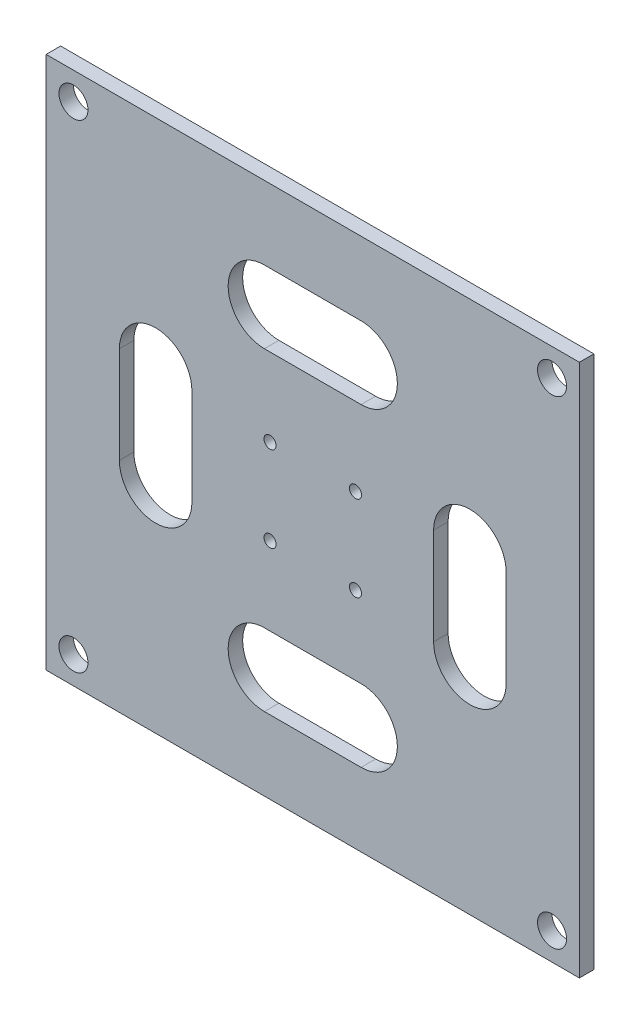
from build123d import *

# Parameters (mm, degrees)
CROQUIS3_W              = 110.308657866
CROQUIS3_H              = 110.308657866
CROQUIS3_R              = 1.25
CROQUIS3_R_2            = 3
SALIENTE_EXTRUIR1_DEPTH = 3


with BuildPart() as part:
    # Croquis3 → Saliente-Extruir1 (new body)
    with BuildSketch(Plane.XY):
        Rectangle(CROQUIS3_W, CROQUIS3_H)
        with Locations((-8.838834765, 8.838834765)):
            Circle(CROQUIS3_R, mode=Mode.SUBTRACT)
        with Locations((8.838834765, 8.838834765)):
            Circle(CROQUIS3_R, mode=Mode.SUBTRACT)
        with Locations((8.838834765, -8.838834765)):
            Circle(CROQUIS3_R, mode=Mode.SUBTRACT)
        with Locations((-8.838834765, -8.838834765)):
            Circle(CROQUIS3_R, mode=Mode.SUBTRACT)
        with Locations((-49.497474683, 49.497474683)):
            Circle(CROQUIS3_R_2, mode=Mode.SUBTRACT)
        with Locations((49.497474683, 49.497474683)):
            Circle(CROQUIS3_R_2, mode=Mode.SUBTRACT)
        with Locations((49.497474683, -49.497474683)):
            Circle(CROQUIS3_R_2, mode=Mode.SUBTRACT)
        with Locations((-49.497474683, -49.497474683)):
            Circle(CROQUIS3_R_2, mode=Mode.SUBTRACT)
        with BuildLine():
            Line((25, -10), (25, 10))
            ThreePointArc((25, 10), (32.5, 17.5), (40, 10))
            Line((40, 10), (40, -10))
            ThreePointArc((40, -10), (32.5, -17.5), (25, -10))
        make_face(mode=Mode.SUBTRACT)
        with BuildLine():
            Line((-25, -10), (-25, 10))
            ThreePointArc((-25, 10), (-32.5, 17.5), (-40, 10))
            Line((-40, 10), (-40, -10))
            ThreePointArc((-40, -10), (-32.5, -17.5), (-25, -10))
        make_face(mode=Mode.SUBTRACT)
        with BuildLine():
            Line((-10, 40), (10, 40))
            ThreePointArc((10, 40), (17.5, 32.5), (10, 25))
            Line((10, 25), (-10, 25))
            ThreePointArc((-10, 25), (-17.5, 32.5), (-10, 40))
        make_face(mode=Mode.SUBTRACT)
        with BuildLine():
            Line((-10, -40), (10, -40))
            ThreePointArc((10, -40), (17.5, -32.5), (10, -25))
            Line((10, -25), (-10, -25))
            ThreePointArc((-10, -25), (-17.5, -32.5), (-10, -40))
        make_face(mode=Mode.SUBTRACT)
    extrude(amount=SALIENTE_EXTRUIR1_DEPTH)


solid = part.part
